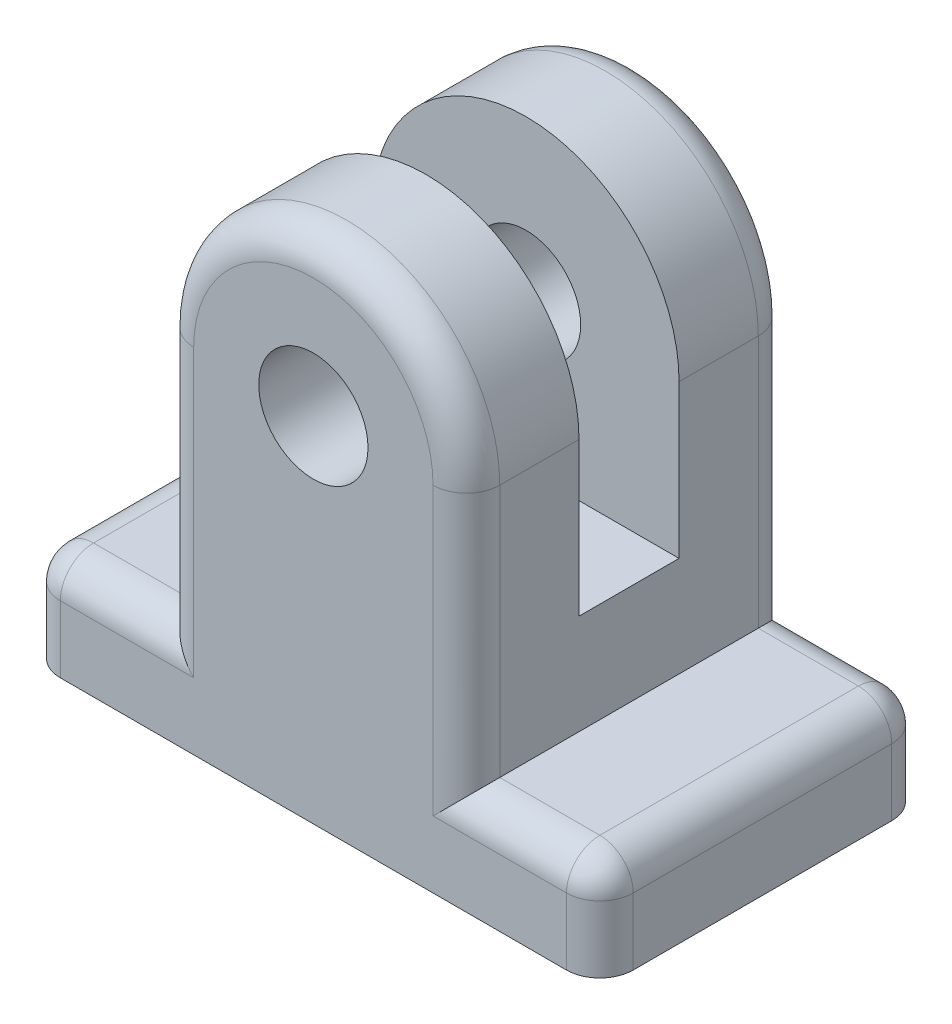
from build123d import *

# Parameters (mm, degrees)
SKETCH1_R           = 1.6375
BOSS_EXTRUDE1_DEPTH = 4.875
SKETCH3_R           = 1.6375
CUT_EXTRUDE1_DEPTH  = 1.5
FILLET1_R           = 1


with BuildPart() as part:
    # Sketch1 → Boss-Extrude1 (new body, symmetric)
    with BuildSketch(Plane.XY):
        with BuildLine():
            Line((-4.5875, 0), (-4.5875, -7.5875))
            Line((-4.5875, -7.5875), (-8.5875, -7.5875))
            Line((-8.5875, -7.5875), (-8.5875, -10.5875))
            Line((-8.5875, -10.5875), (8.5875, -10.5875))
            Line((8.5875, -10.5875), (8.5875, -7.5875))
            Line((8.5875, -7.5875), (4.5875, -7.5875))
            Line((4.5875, -7.5875), (4.5875, 0))
            ThreePointArc((4.5875, 0), (0, 4.5875), (-4.5875, 0))
        make_face()
        Circle(SKETCH1_R, mode=Mode.SUBTRACT)
    extrude(amount=BOSS_EXTRUDE1_DEPTH, both=True)

    # Sketch3 → Cut-Extrude1 (cut, symmetric)
    with BuildSketch(Plane.XY):
        with BuildLine():
            Line((-4.5875, 0), (-4.5875, -4.5875))
            Line((-4.5875, -4.5875), (4.5875, -4.5875))
            Line((4.5875, -4.5875), (4.5875, 0))
            ThreePointArc((4.5875, 0), (0, 4.5875), (-4.5875, 0))
        make_face()
        Circle(SKETCH3_R, mode=Mode.SUBTRACT)
    extrude(amount=CUT_EXTRUDE1_DEPTH, both=True, mode=Mode.SUBTRACT)

    # Fillet1
    fillet1_edges = [part.edges().sort_by_distance(p)[0] for p in [
        (-6.5875, -7.5875, 4.875),
        (-4.5875, -3.79375, -4.875),
        (0, 4.5875, -4.875),
        (-8.5875, -9.0875, 4.875),
        (8.5875, -7.5875, 0),
        (-8.5875, -7.5875, 0),
        (8.5875, -9.0875, 4.875),
        (6.5875, -7.5875, 4.875),
        (4.5875, -3.79375, 4.875),
        (0, 4.5875, 4.875),
        (-4.5875, -3.79375, 4.875),
        (4.5875, -3.79375, -4.875),
        (6.5875, -7.5875, -4.875),
        (8.5875, -9.0875, -4.875),
        (-8.5875, -9.0875, -4.875),
        (-6.5875, -7.5875, -4.875),
    ]]
    fillet(fillet1_edges, radius=FILLET1_R)


solid = part.part
